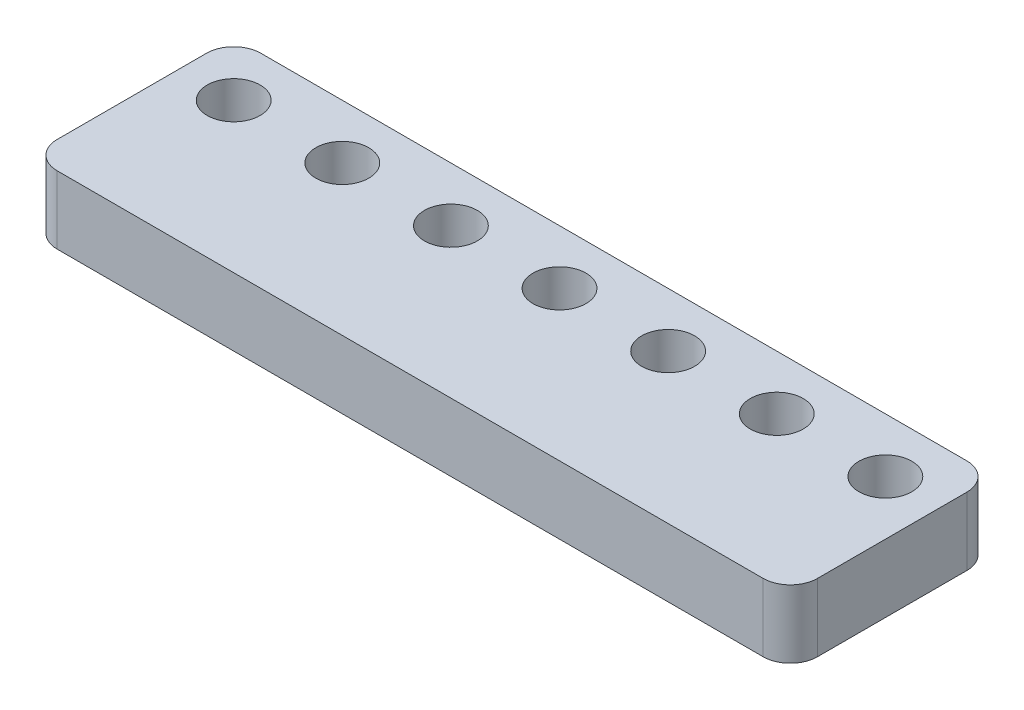
from build123d import *

# Parameters (mm, degrees)
BOSS_EXTRUDE1_DEPTH = 5
SKETCH2_R           = 1.95
CUT_EXTRUDE1_DEPTH  = 6


with BuildPart() as part:
    # Sketch1 → Boss-Extrude1 (new body)
    with BuildSketch(Plane(origin=(0, 0, 0), x_dir=(1, 0, 0), z_dir=(0, 1, 0))):
        with BuildLine():
            Line((-54, 0), (-2, 0))
            ThreePointArc((-2, 0), (-0.585786438, -0.585786438), (0, -2))
            Line((0, -2), (0, -13))
            ThreePointArc((0, -13), (-0.585786438, -14.414213562), (-2, -15))
            Line((-2, -15), (-54, -15))
            ThreePointArc((-54, -15), (-55.414213562, -14.414213562), (-56, -13))
            Line((-56, -13), (-56, -2))
            ThreePointArc((-56, -2), (-55.414213562, -0.585786438), (-54, 0))
        make_face()
    extrude(amount=BOSS_EXTRUDE1_DEPTH)

    # Sketch2 → Cut-Extrude1 (cut, through all)
    with BuildSketch(Plane(origin=(0, 5, 0), x_dir=(1, 0, 0), z_dir=(0, 1, 0))):
        with Locations((-4, -4)):
            Circle(SKETCH2_R)
        with Locations((-12, -4)):
            Circle(SKETCH2_R)
        with Locations((-76, -4)):
            Circle(SKETCH2_R)
        with Locations((-68, -4)):
            Circle(SKETCH2_R)
        with Locations((-60, -4)):
            Circle(SKETCH2_R)
        with Locations((-52, -4)):
            Circle(SKETCH2_R)
        with Locations((-44, -4)):
            Circle(SKETCH2_R)
        with Locations((-36, -4)):
            Circle(SKETCH2_R)
        with Locations((-28, -4)):
            Circle(SKETCH2_R)
        with Locations((-20, -4)):
            Circle(SKETCH2_R)
    extrude(amount=-CUT_EXTRUDE1_DEPTH, mode=Mode.SUBTRACT)


solid = part.part
